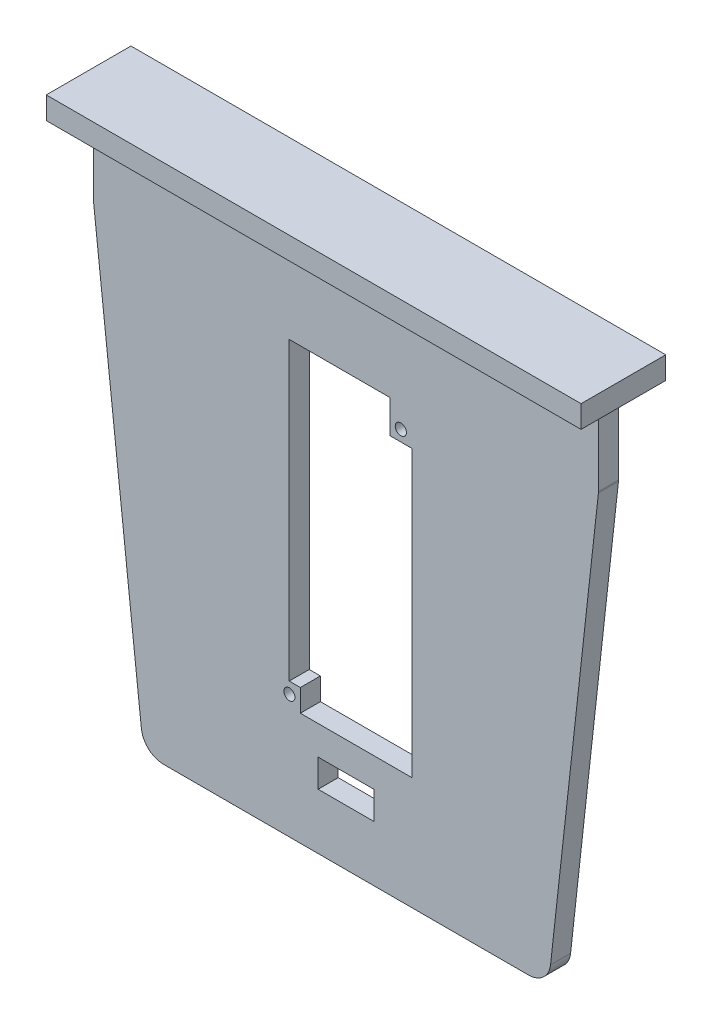
from build123d import *

# Parameters (mm, degrees)
BOSS_EXTRUDE1_DEPTH = 4.572
SKETCH3_W           = 115.1315452
SKETCH3_H           = 4.572
BOSS_EXTRUDE2_DEPTH = 17.78
FILLET1_R           = 2.54
SKETCH4_W           = 121.92
SKETCH4_H           = 19.304
BOSS_EXTRUDE4_DEPTH = 5.08
SKETCH5_W           = 12.7
SKETCH5_H           = 6.35
CUT_EXTRUDE1_DEPTH  = 5.08
SKETCH6_R           = 1.27
CUT_EXTRUDE2_DEPTH  = 6.35


with BuildPart() as part:
    # Sketch2 → Boss-Extrude1 (new body)
    with BuildSketch(Plane(origin=(0, 0, 0), x_dir=(-1, 0, 0), z_dir=(0, 0, -1))):
        with BuildLine():
            Line((-62.487415839, 48.848476089), (52.644129361, 48.848476089))
            Line((52.644129361, 48.848476089), (41.713156468, -49.932022311))
            ThreePointArc((41.713156468, -49.932022311), (40.052782988, -53.157778108), (36.663977171, -54.453284069))
            Line((36.663977171, -54.453284069), (-46.507263649, -54.453284069))
            ThreePointArc((-46.507263649, -54.453284069), (-49.896069466, -53.157778108), (-51.556442946, -49.932022311))
            Line((-51.556442946, -49.932022311), (-62.487415839, 48.848476089))
        make_face()
    extrude(amount=BOSS_EXTRUDE1_DEPTH)

    # Sketch3 → Boss-Extrude2 (add)
    with BuildSketch(Plane(origin=(0, 48.848476089, 0), x_dir=(1, 0, 0), z_dir=(0, 1, 0))):
        with Locations((4.921643239, 2.286)):
            Rectangle(SKETCH3_W, SKETCH3_H)
    extrude(amount=BOSS_EXTRUDE2_DEPTH)

    # Fillet1
    fillet1_edges = [part.edges().sort_by_distance(p)[0] for p in [
        (62.487415839, 48.848476089, -2.286),
        (-52.644129361, 48.848476089, -2.286),
    ]]
    fillet(fillet1_edges, radius=FILLET1_R)

    # Sketch4 → Boss-Extrude4 (add)
    with BuildSketch(Plane(origin=(0, 66.628476089, 0), x_dir=(1, 0, 0), z_dir=(0, 1, 0))):
        with Locations((4.921643239, 2.286)):
            Rectangle(SKETCH4_W, SKETCH4_H)
    extrude(amount=BOSS_EXTRUDE4_DEPTH)

    # Sketch5 → Cut-Extrude1 (cut)
    with BuildSketch(Plane(origin=(0, 0, -4.572), x_dir=(-1, 0, 0), z_dir=(0, 0, -1))):
        with Locations((-4.921643239, -38.578284069)):
            Rectangle(SKETCH5_W, SKETCH5_H)
    extrude(amount=-CUT_EXTRUDE1_DEPTH, mode=Mode.SUBTRACT)

    # Sketch6 → Cut-Extrude2 (cut)
    with BuildSketch(Plane(origin=(0, 0, -4.572), x_dir=(-1, 0, 0), z_dir=(0, 0, -1))):
        Polygon((-14.921643239, 43.768476089), (-14.921643239, 41.228476089), (-14.921643239, 36.228476089), (-19.921643239, 36.228476089), (-19.921643239, -28.771523911), (5.478356761, -28.771523911), (5.478356761, -23.691523911), (8.018356761, -23.691523911), (8.018356761, 43.768476089), align=None)
        with Locations((-17.421643239, 38.728476089)):
            Circle(SKETCH6_R)
        with Locations((7.978356761, -26.271523911)):
            Circle(SKETCH6_R)
    extrude(amount=-CUT_EXTRUDE2_DEPTH, mode=Mode.SUBTRACT)


solid = part.part
